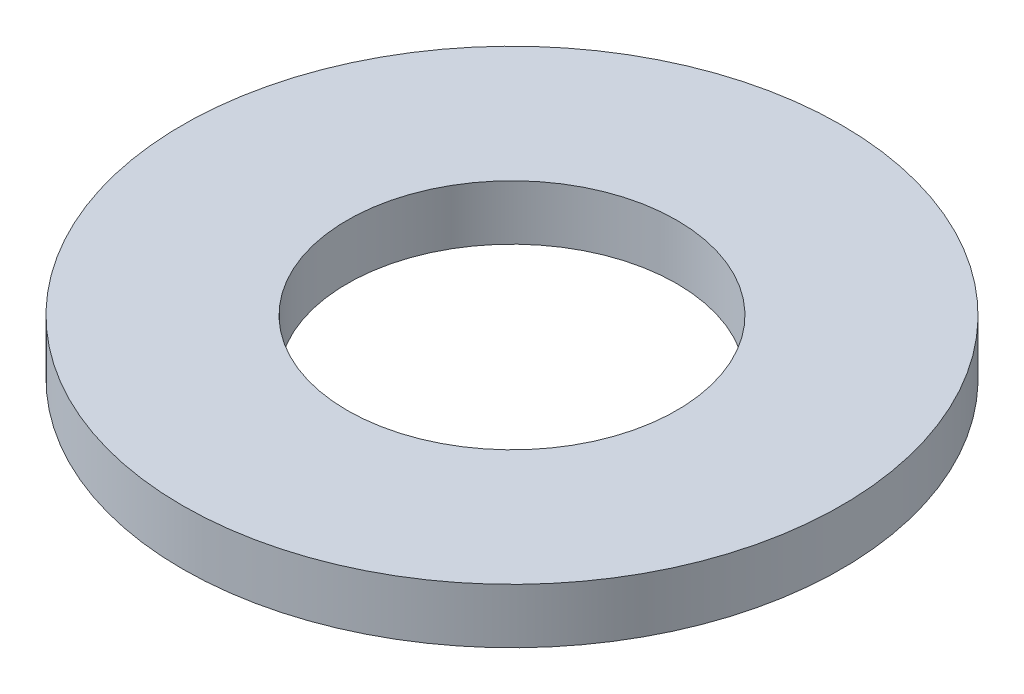
from build123d import *

# Parameters (mm, degrees)
SKETCH_1_R      = 3
SKETCH_1_R_2    = 1.5
EXTRUDE_1_DEPTH = 0.5


with BuildPart() as part:
    # 草图1 → 凸台-拉伸1 (new body)
    with BuildSketch(Plane(origin=(0, 0, 0), x_dir=(1, 0, 0), z_dir=(0, 1, 0))):
        Circle(SKETCH_1_R)
        Circle(SKETCH_1_R_2, mode=Mode.SUBTRACT)
    extrude(amount=EXTRUDE_1_DEPTH)


solid = part.part
